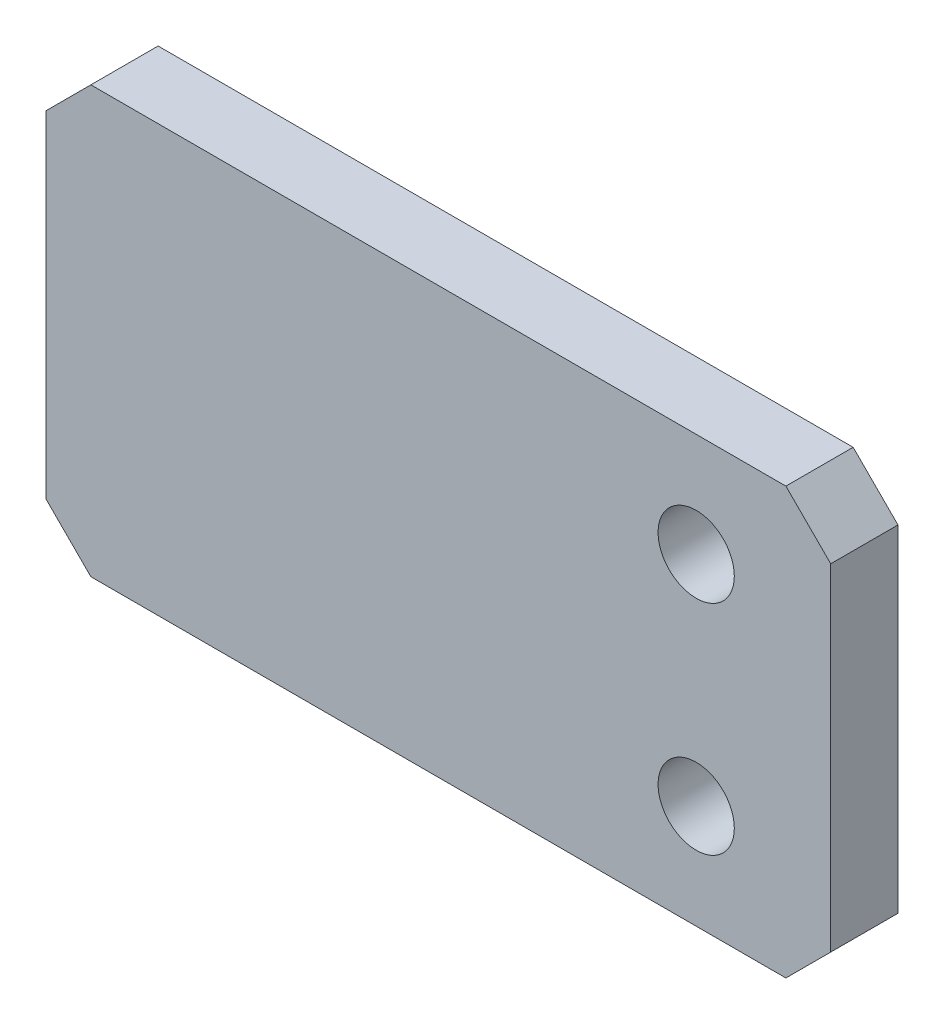
from build123d import *

# Parameters (mm, degrees)
SKETCH1_W                = 35
SKETCH1_H                = 19
BOSS_EXTRUDE1_DEPTH      = 3
CHAMFER1_SIZE            = 2
M3_CLEARANCE_HOLE1_D     = 3.4
M3_CLEARANCE_HOLE1_DEPTH = 3


with BuildPart() as part:
    # Sketch1 → Boss-Extrude1 (new body)
    with BuildSketch(Plane.XY):
        Rectangle(SKETCH1_W, SKETCH1_H)
    extrude(amount=BOSS_EXTRUDE1_DEPTH)

    # Chamfer1
    chamfer1_edges = [part.edges().sort_by_distance(p)[0] for p in [
        (17.5, -9.5, 1.5),
        (-17.5, -9.5, 1.5),
        (-17.5, 9.5, 1.5),
        (17.5, 9.5, 1.5),
    ]]
    chamfer(chamfer1_edges, length=CHAMFER1_SIZE)

    # M3 Clearance Hole1
    with Locations(Plane.XY.offset(3)):
        with Locations((11.5, 4.866311679), (11.5, -4.866311679)):
            Hole(M3_CLEARANCE_HOLE1_D / 2, depth=M3_CLEARANCE_HOLE1_DEPTH)


solid = part.part
